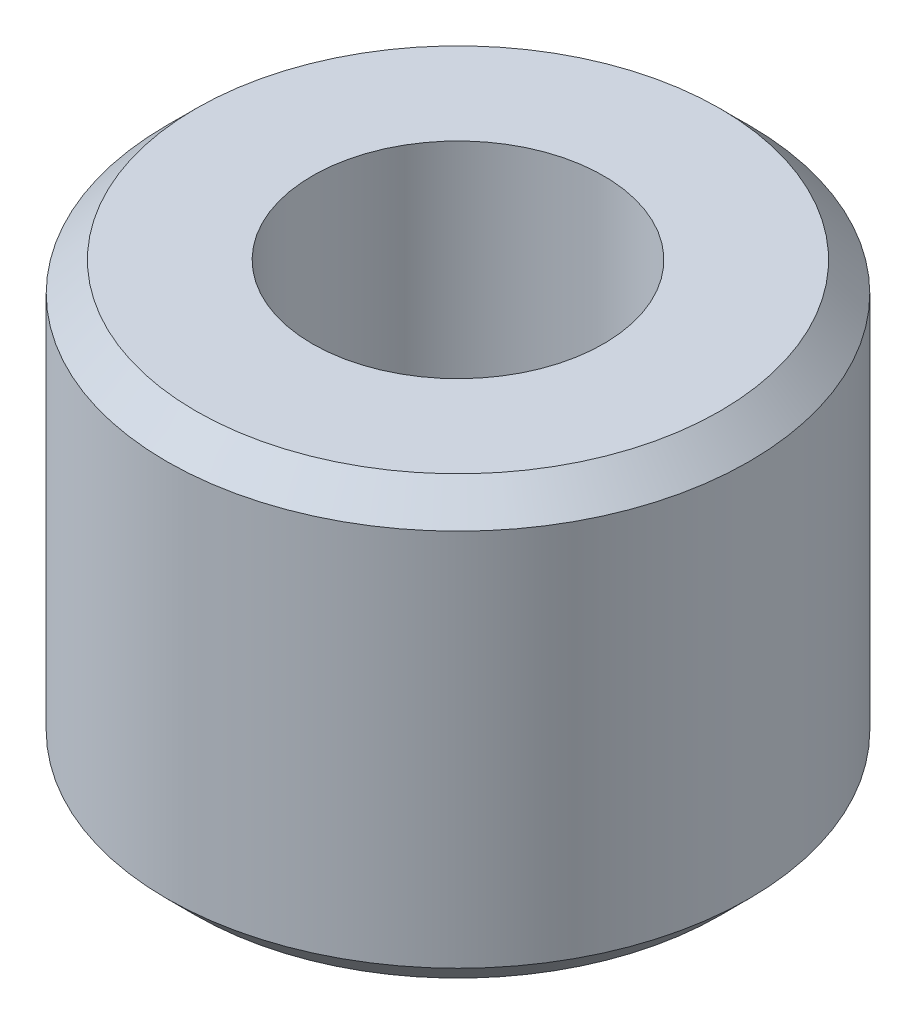
from build123d import *

# Parameters (mm, degrees)
SKETCH1_R           = 10
SKETCH1_R_2         = 5
BOSS_EXTRUDE1_DEPTH = 15
CHAMFER2_SIZE       = 1


with BuildPart() as part:
    # Sketch1 → Boss-Extrude1 (new body)
    with BuildSketch(Plane(origin=(0, 0, 0), x_dir=(1, 0, 0), z_dir=(0, 1, 0))):
        Circle(SKETCH1_R)
        Circle(SKETCH1_R_2, mode=Mode.SUBTRACT)
    extrude(amount=BOSS_EXTRUDE1_DEPTH)

    # Chamfer2
    chamfer2_edges = [part.edges().sort_by_distance(p)[0] for p in [
        (-10, 0, 0),
        (-10, 15, 0),
    ]]
    chamfer(chamfer2_edges, length=CHAMFER2_SIZE)


solid = part.part
